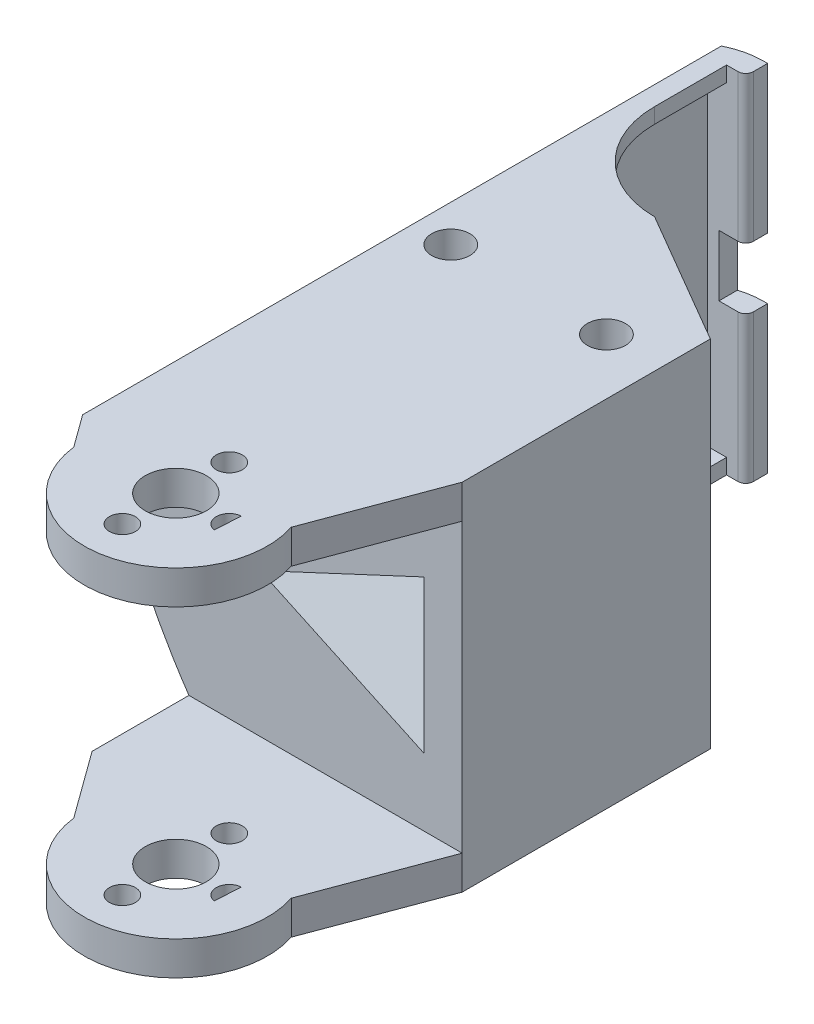
from build123d import *

# Parameters (mm, degrees)
BOSS_EXTRUDE1_DEPTH  = 32.5
SKETCH4_R            = 1.05
BOSS_EXTRUDE2_DEPTH  = 2
SKETCH7_R            = 2.495
WIRE_SPACING2_DEPTH  = 3
SKETCH8_W            = 35
SKETCH8_H            = 37.7
SKETCH8_R            = 2.495
BOSS_EXTRUDE6_DEPTH  = 2
SKETCH5_R            = 1.05
BOSS_EXTRUDE3_DEPTH  = 2
SKETCH9_R            = 2.495
WIRE_SPACING1_DEPTH  = 3
SKETCH10_W           = 35
SKETCH10_H           = 37.7
SKETCH10_R           = 2.495
BOSS_EXTRUDE8_DEPTH  = 2
SKETCH11_R           = 12.5
CUT_EXTRUDE1_DEPTH   = 47.5
CUT_EXTRUDE2_DEPTH   = 47.5
SKETCH13_W           = 45
SKETCH13_H           = 46.5
BOSS_EXTRUDE9_DEPTH  = 17.5
SKETCH15_W           = 12.5
SKETCH15_H           = 46.5
BOSS_EXTRUDE10_DEPTH = 50
SKETCH18_R           = 4
SKETCH18_R_2         = 1.7
BOSS_EXTRUDE11_DEPTH = 46.5
BOSS_EXTRUDE13_DEPTH = 46.5
SKETCH21_W           = 89.912502986
SKETCH21_H           = 37.65
CUT_EXTRUDE3_DEPTH   = 46
CUT_EXTRUDE5_DEPTH   = 47.5
CUT_EXTRUDE4_START   = -50.5000001
CUT_EXTRUDE4_DEPTH   = 101.5000002
CUT_EXTRUDE6_DEPTH   = 53.0000001
BOSS_EXTRUDE14_DEPTH = 46.5
FILLET2_R            = 10
SKETCH29_W           = 2.5
SKETCH29_H           = 42.5
CUT_EXTRUDE8_DEPTH   = 9.427041
FILLET3_R            = 1
SKETCH30_W           = 7.311581117
SKETCH30_H           = 8
CUT_EXTRUDE9_DEPTH   = 22.5


with BuildPart() as part:
    # Sketch2 → Boss-Extrude1 (new body)
    with BuildSketch(Plane(origin=(0, 0, 0), x_dir=(1, 0, 0), z_dir=(0, 1, 0))):
        Polygon((17.5, 0), (17.5, 37.7), (15, 37.7), (15, 2.5), (-15, 2.5), (-15, 37.7), (-17.5, 37.7), (-17.5, 0), align=None)
    extrude(amount=BOSS_EXTRUDE1_DEPTH)

    # Sketch4 → Boss-Extrude2 (add)
    with BuildSketch(Plane.XZ):
        Polygon((-17.5, 0), (-17.5, -7.443777264), (-17.5, -37.7), (-15, -37.7), (-15, -7.5), (15, -7.5), (15, -37.7), (17.5, -37.7), (17.5, -7.443777264), (17.5, 0), align=None)
        with Locations((-10.1889, -4.95)):
            Circle(SKETCH4_R, mode=Mode.SUBTRACT)
        with Locations((10.1889, -4.95)):
            Circle(SKETCH4_R, mode=Mode.SUBTRACT)
    extrude(amount=BOSS_EXTRUDE2_DEPTH)

    # Sketch7 → Wire spacing2 (add)
    with BuildSketch(Plane.XZ.offset(2)):
        Polygon((-17.5, 0), (-17.5, -37.7), (-15, -37.7), (-15, -7.5), (15, -7.5), (15, -37.7), (17.5, -37.7), (17.5, 0), align=None)
        with Locations((-10.1889, -4.95)):
            Circle(SKETCH7_R, mode=Mode.SUBTRACT)
        with Locations((10.1889, -4.95)):
            Circle(SKETCH7_R, mode=Mode.SUBTRACT)
    extrude(amount=WIRE_SPACING2_DEPTH)

    # Sketch8 → Boss-Extrude6 (add)
    with BuildSketch(Plane.XZ.offset(5)):
        with Locations((0, -18.85)):
            Rectangle(SKETCH8_W, SKETCH8_H)
        with Locations((-10.1889, -4.95)):
            Circle(SKETCH8_R, mode=Mode.SUBTRACT)
        with Locations((10.1889, -4.95)):
            Circle(SKETCH8_R, mode=Mode.SUBTRACT)
    extrude(amount=BOSS_EXTRUDE6_DEPTH)

    # Sketch5 → Boss-Extrude3 (add)
    with BuildSketch(Plane(origin=(0, 32.5, 0), x_dir=(1, 0, 0), z_dir=(0, 1, 0))):
        Polygon((-7.439, 10), (-7.439, 2.5), (7.439, 2.5), (7.439, 10), (10.1889, 12), (15, 12), (15, 37.7), (17.5, 37.7), (17.5, 0), (-17.5, 0), (-17.5, 37.7), (-15, 37.7), (-15, 12), (-10.1889, 12), align=None)
        with Locations((-10.1889, 8.7)):
            Circle(SKETCH5_R, mode=Mode.SUBTRACT)
        with Locations((10.1889, 8.7)):
            Circle(SKETCH5_R, mode=Mode.SUBTRACT)
    extrude(amount=BOSS_EXTRUDE3_DEPTH)

    # Sketch9 → Wire spacing1 (add)
    with BuildSketch(Plane(origin=(0, 34.5, 0), x_dir=(1, 0, 0), z_dir=(0, 1, 0))):
        Polygon((-17.5, 0), (-17.5, 37.7), (-15, 37.7), (-15, 12), (-10.1889, 12), (-7.439, 10), (-7.439, 2.5), (7.439, 2.5), (7.439, 10), (10.1889, 12), (15, 12), (15, 37.7), (17.5, 37.7), (17.5, 0), align=None)
        with Locations((-10.1889, 8.7)):
            Circle(SKETCH9_R, mode=Mode.SUBTRACT)
        with Locations((10.1889, 8.7)):
            Circle(SKETCH9_R, mode=Mode.SUBTRACT)
    extrude(amount=WIRE_SPACING1_DEPTH)

    # Sketch10 → Boss-Extrude8 (add)
    with BuildSketch(Plane(origin=(0, 37.5, 0), x_dir=(1, 0, 0), z_dir=(0, 1, 0))):
        with Locations((0, 18.85)):
            Rectangle(SKETCH10_W, SKETCH10_H)
        with Locations((-10.1889, 8.7)):
            Circle(SKETCH10_R, mode=Mode.SUBTRACT)
        with Locations((10.1889, 8.7)):
            Circle(SKETCH10_R, mode=Mode.SUBTRACT)
    extrude(amount=BOSS_EXTRUDE8_DEPTH)

    # Sketch11 → Cut-Extrude1 (cut, through all)
    with BuildSketch(Plane(origin=(0, 39.5, 0), x_dir=(1, 0, 0), z_dir=(0, 1, 0))):
        with Locations((0, 37.7)):
            Circle(SKETCH11_R)
    extrude(amount=-CUT_EXTRUDE1_DEPTH, mode=Mode.SUBTRACT)

    # Sketch12 → Cut-Extrude2 (cut, through all)
    with BuildSketch(Plane.XZ.offset(7)):
        Polygon((0, -25.2), (17.5, -15), (17.5, -47.484525272), align=None)
    extrude(amount=-CUT_EXTRUDE2_DEPTH, mode=Mode.SUBTRACT)

    # Sketch13 → Boss-Extrude9 (add)
    with BuildSketch(Plane.XY):
        with Locations((-5, 16.25)):
            Rectangle(SKETCH13_W, SKETCH13_H)
    extrude(amount=BOSS_EXTRUDE9_DEPTH)

    # Sketch15 → Boss-Extrude10 (add)
    with BuildSketch(Plane(origin=(0, 0, 0), x_dir=(-1, 0, 0), z_dir=(0, 0, -1))):
        with Locations((21.25, 16.25)):
            Rectangle(SKETCH15_W, SKETCH15_H)
    extrude(amount=BOSS_EXTRUDE10_DEPTH)

    # Sketch18 → Boss-Extrude11 (add)
    with BuildSketch(Plane.XZ.offset(7)):
        with BuildLine():
            Line((12.5, 22.5), (12.5, 17.5))
            Line((12.5, 17.5), (-12.5, 17.5))
            Line((-12.5, 17.5), (-12.5, 22.5))
            Line((-12.5, 22.5), (-9.367496998, 30))
            ThreePointArc((-9.367496998, 30), (0, 49.5), (9.367496998, 30))
            Line((9.367496998, 30), (12.5, 22.5))
        make_face()
        with Locations((0, 37.5)):
            Circle(SKETCH18_R, mode=Mode.SUBTRACT)
        with Locations((0, 30.5)):
            Circle(SKETCH18_R_2, mode=Mode.SUBTRACT)
        with Locations((-7, 37.5)):
            Circle(SKETCH18_R_2, mode=Mode.SUBTRACT)
        with Locations((0, 44.5)):
            Circle(SKETCH18_R_2, mode=Mode.SUBTRACT)
        with Locations((7, 37.5)):
            Circle(SKETCH18_R_2, mode=Mode.SUBTRACT)
    extrude(amount=-BOSS_EXTRUDE11_DEPTH)

    # Sketch22 → Boss-Extrude13 (add)
    with BuildSketch(Plane.XZ.offset(7)):
        Polygon((-27.5, 17.5), (-5.066300312, 48.378078928), (-5.066300312, 17.5), align=None)
        Polygon((17.5, 17.5), (6.194336088, 47.777655396), (7.922300343, 17.5), align=None)
    extrude(amount=-BOSS_EXTRUDE13_DEPTH)

    # Sketch21 → Cut-Extrude3 (cut, through all)
    with BuildSketch(Plane.ZY.offset(27.5)):
        with Locations((62.456251493, 16.25)):
            Rectangle(SKETCH21_W, SKETCH21_H)
    extrude(amount=-CUT_EXTRUDE3_DEPTH, mode=Mode.SUBTRACT)

    # Sketch26 → Cut-Extrude5 (cut, through all)
    with BuildSketch(Plane(origin=(0, 39.5, 0), x_dir=(1, 0, 0), z_dir=(0, 1, 0))):
        with BuildLine():
            Line((-27.5, 29.387171818), (-27.5, 50))
            Line((-27.5, 50), (-15, 50))
            add(Edge.make_bspline(
                [(-15, 50), (-23.594741162, 41.153529081), (-27.5, 29.387171818)],
                knots=[0, 0, 0, 1, 1, 1], degree=2))
        make_face()
    extrude(amount=-CUT_EXTRUDE5_DEPTH, mode=Mode.SUBTRACT)

    # Sketch24 → Cut-Extrude4 (cut)
    with BuildSketch(Plane(origin=(0, 0, 0), x_dir=(-1, 0, 0), z_dir=(0, 0, -1)).offset(CUT_EXTRUDE4_START)):
        with BuildLine():
            Line((15, -7), (27.5, -7))
            Line((27.5, -7), (27.5, 16.25))
            add(Edge.make_bspline(
                [(27.5, 16.25), (23.398461901, 3.482399142), (15, -7)],
                knots=[0, 0, 0, 1, 1, 1], degree=2))
        make_face()
    cut_extrude4 = extrude(amount=CUT_EXTRUDE4_DEPTH, mode=Mode.SUBTRACT)

    # Mirror1: Cut-Extrude4 across plane
    add(cut_extrude4.mirror(Plane(origin=(0, 16.25, 0), x_dir=(0, 0, 1), z_dir=(0, -1, 0))), mode=Mode.SUBTRACT)

    # Sketch27 → Cut-Extrude6 (cut, through all)
    with BuildSketch(Plane(origin=(0, 0, -2.5), x_dir=(-1, 0, 0), z_dir=(0, 0, -1))):
        Polygon((-12.5, 26.25), (8.945069205, 16.25), (-12.5, 6.25), align=None)
    extrude(amount=-CUT_EXTRUDE6_DEPTH, mode=Mode.SUBTRACT)

    # Sketch28 → Boss-Extrude14 (add)
    with BuildSketch(Plane(origin=(0, 39.5, 0), x_dir=(1, 0, 0), z_dir=(0, 1, 0))):
        Polygon((-15, 37.7), (-15, 50), (-10, 50), (-10, 47.127040762), (-12.5, 47.127040762), (-12.5, 37.7), align=None)
    extrude(amount=-BOSS_EXTRUDE14_DEPTH)

    # Fillet2
    fillet2_edges = [part.edges().sort_by_distance(p)[0] for p in [
        (-15, 16.25, -50),
    ]]
    fillet(fillet2_edges, radius=FILLET2_R)

    # Sketch29 → Cut-Extrude8 (cut)
    with BuildSketch(Plane.XY.offset(-37.7)):
        with Locations((-13.75, 16.25)):
            Rectangle(SKETCH29_W, SKETCH29_H)
    extrude(amount=-CUT_EXTRUDE8_DEPTH, mode=Mode.SUBTRACT)

    # Fillet3
    fillet3_edges = [part.edges().sort_by_distance(p)[0] for p in [
        (-10, 16.25, -47.127040762),
    ]]
    fillet(fillet3_edges, radius=FILLET3_R)

    # Sketch30 → Cut-Extrude9 (cut)
    with BuildSketch(Plane.XY.offset(-47.127040762)):
        with Locations((-9.844209442, 16.25)):
            Rectangle(SKETCH30_W, SKETCH30_H)
    extrude(amount=-CUT_EXTRUDE9_DEPTH, mode=Mode.SUBTRACT)


solid = part.part
